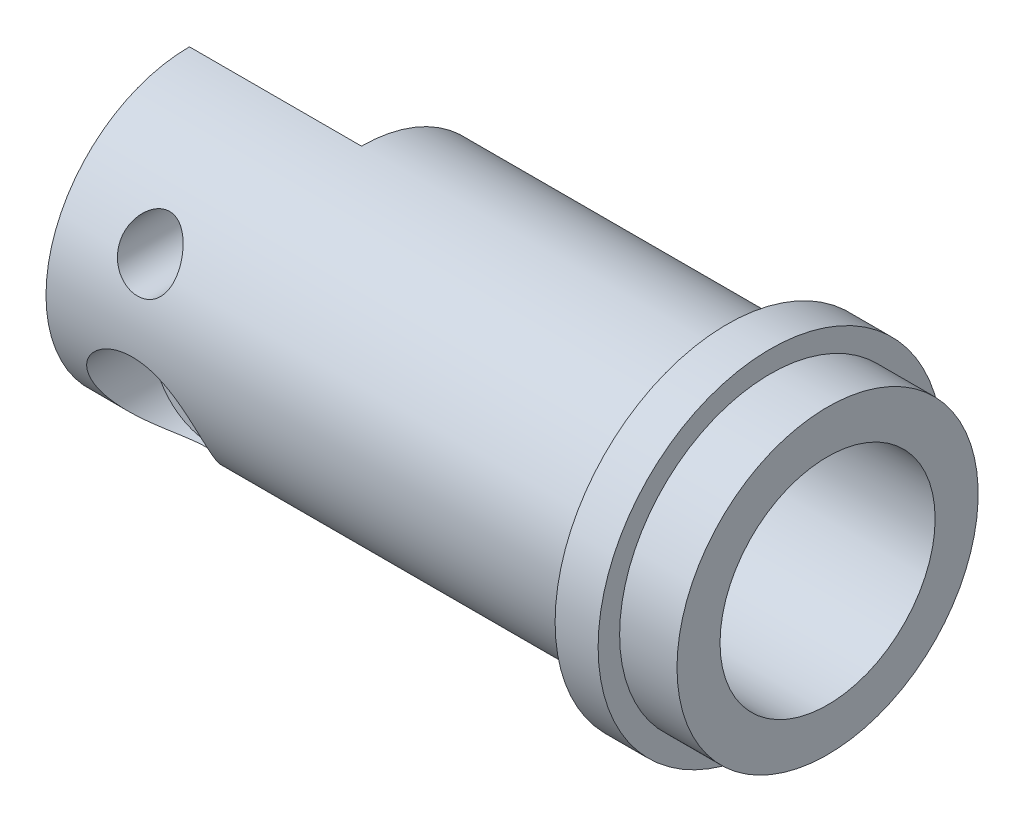
from build123d import *

# Parameters (mm, degrees)
DODANIE_WYCI_GNI_CIE1_DEPTH = 12
SZKIC3_R                    = 2
WYTNIJ_WYCI_GNI_CIE1_DEPTH  = 12
SZKIC6_R                    = 4
WYTNIJ_WYCI_GNI_CIE2_DEPTH  = 12
SZKIC7_R                    = 3
WYTNIJ_WYCI_GNI_CIE3_DEPTH  = 14.5
SZKIC9_R                    = 2.5
WYTNIJ_WYCI_GNI_CIE5_DEPTH  = 13


with BuildPart() as part:
    # Szkic1 → Obrót1 (revolve)
    with BuildSketch(Plane(origin=(0, 0, 0), x_dir=(1, 0, 0), z_dir=(0, 1, 0))):
        Polygon((28.285714286, 0), (40.785714286, 0), (40.785714286, 7.5), (60.785714286, 7.5), (60.785714286, 10.5), (56.785714286, 10.5), (56.785714286, 12), (53.785714286, 12), (53.785714286, 10), (28.285714286, 10), align=None)
    revolve(axis=Axis((28.285714286, 0, 0), (1, 0, 0)))

    # Szkic2 → Dodanie-wyciągnięcie1 (add)
    with BuildSketch(Plane.ZY.offset(-28.285714286)):
        with BuildLine():
            Line((0, -10), (0, 10))
            ThreePointArc((0, 10), (10, 0), (0, -10))
        make_face()
    extrude(amount=DODANIE_WYCI_GNI_CIE1_DEPTH)

    # Szkic3 → Wytnij-wyciągnięcie1 (cut)
    with BuildSketch(Plane.XY):
        with Locations((22.285714286, 4.75)):
            Circle(SZKIC3_R)
        with Locations((22.285714286, -4.75)):
            Circle(SZKIC3_R)
    extrude(amount=WYTNIJ_WYCI_GNI_CIE1_DEPTH, mode=Mode.SUBTRACT)

    # Szkic6 → Wytnij-wyciągnięcie2 (cut)
    with BuildSketch(Plane(origin=(0, 0, 4.5), x_dir=(-1, 0, 0), z_dir=(0, 0, -1))):
        with Locations((-22.285714286, -4.75)):
            Circle(SZKIC6_R)
    extrude(amount=-WYTNIJ_WYCI_GNI_CIE2_DEPTH, mode=Mode.SUBTRACT)

    # Szkic7 → Wytnij-wyciągnięcie3 (cut)
    with BuildSketch(Plane(origin=(40.785714286, 0, 0), x_dir=(0, 0, -1), z_dir=(1, 0, 0))):
        Circle(SZKIC7_R)
    extrude(amount=-WYTNIJ_WYCI_GNI_CIE3_DEPTH, mode=Mode.SUBTRACT)

    # Szkic9 → Wytnij-wyciągnięcie5 (cut, through all)
    with BuildSketch(Plane.XY):
        with Locations((28.285714286, 0)):
            Circle(SZKIC9_R)
    extrude(amount=-WYTNIJ_WYCI_GNI_CIE5_DEPTH, mode=Mode.SUBTRACT)


solid = part.part
